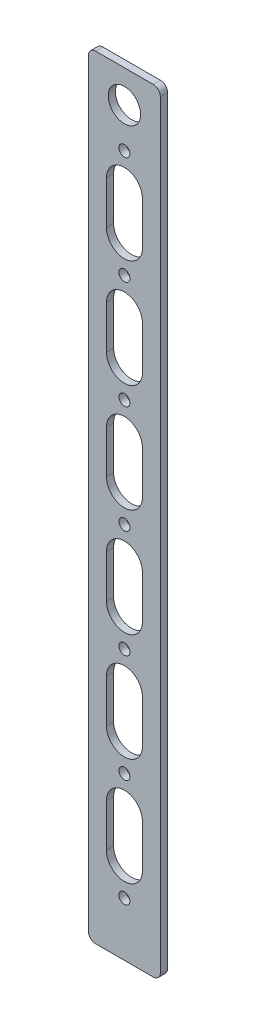
from build123d import *

# Parameters (mm, degrees)
SKETCH_1_W          = 20
SKETCH_1_H          = 215
EXTRUDE_1_DEPTH     = 2
FILLET_1_R          = 2
SKETCH_2_R          = 1.525
CUT_EXTRUDE_1_DEPTH = 10
SKETCH_4_R          = 4.5
CUT_EXTRUDE_2_DEPTH = 10


with BuildPart() as part:
    # 草图1 → 凸台-拉伸1 (new body)
    with BuildSketch(Plane.XY):
        Rectangle(SKETCH_1_W, SKETCH_1_H)
    extrude(amount=EXTRUDE_1_DEPTH)

    # 圆角1
    fillet_1_edges = [part.edges().sort_by_distance(p)[0] for p in [
        (10, -107.5, 1),
        (-10, -107.5, 1),
        (-10, 107.5, 1),
        (10, 107.5, 1),
    ]]
    fillet(fillet_1_edges, radius=FILLET_1_R)

    # 草图2 → 切除-拉伸1 (cut)
    with BuildSketch(Plane.XY.offset(2)):
        with Locations((0, 87.5)):
            Circle(SKETCH_2_R)
        with Locations((0, 57.5)):
            Circle(SKETCH_2_R)
        with Locations((0, 27.5)):
            Circle(SKETCH_2_R)
        with Locations((0, -2.5)):
            Circle(SKETCH_2_R)
        with Locations((0, -32.5)):
            Circle(SKETCH_2_R)
        with Locations((0, -62.5)):
            Circle(SKETCH_2_R)
        with Locations((0, -92.5)):
            Circle(SKETCH_2_R)
    extrude(amount=-CUT_EXTRUDE_1_DEPTH, mode=Mode.SUBTRACT)

    # 草图4 → 切除-拉伸2 (cut)
    with BuildSketch(Plane.XY.offset(2)):
        with Locations((0, 98.5)):
            Circle(SKETCH_4_R)
        with BuildLine():
            Line((5, 66.5), (5, 78.5))
            ThreePointArc((5, 78.5), (0, 83.5), (-5, 78.5))
            Line((-5, 78.5), (-5, 66.5))
            ThreePointArc((-5, 66.5), (0, 61.5), (5, 66.5))
        make_face()
        with BuildLine():
            Line((5, 36.5), (5, 48.5))
            ThreePointArc((5, 48.5), (0, 53.5), (-5, 48.5))
            Line((-5, 48.5), (-5, 36.5))
            ThreePointArc((-5, 36.5), (0, 31.5), (5, 36.5))
        make_face()
        with BuildLine():
            Line((5, -83.5), (5, -71.5))
            ThreePointArc((5, -71.5), (0, -66.5), (-5, -71.5))
            Line((-5, -71.5), (-5, -83.5))
            ThreePointArc((-5, -83.5), (0, -88.5), (5, -83.5))
        make_face()
        with BuildLine():
            Line((5, 6.5), (5, 18.5))
            ThreePointArc((5, 18.5), (0, 23.5), (-5, 18.5))
            Line((-5, 18.5), (-5, 6.5))
            ThreePointArc((-5, 6.5), (0, 1.5), (5, 6.5))
        make_face()
        with BuildLine():
            Line((5, -23.5), (5, -11.5))
            ThreePointArc((5, -11.5), (0, -6.5), (-5, -11.5))
            Line((-5, -11.5), (-5, -23.5))
            ThreePointArc((-5, -23.5), (0, -28.5), (5, -23.5))
        make_face()
        with BuildLine():
            Line((5, -53.5), (5, -41.5))
            ThreePointArc((5, -41.5), (0, -36.5), (-5, -41.5))
            Line((-5, -41.5), (-5, -53.5))
            ThreePointArc((-5, -53.5), (0, -58.5), (5, -53.5))
        make_face()
    extrude(amount=-CUT_EXTRUDE_2_DEPTH, mode=Mode.SUBTRACT)


solid = part.part
